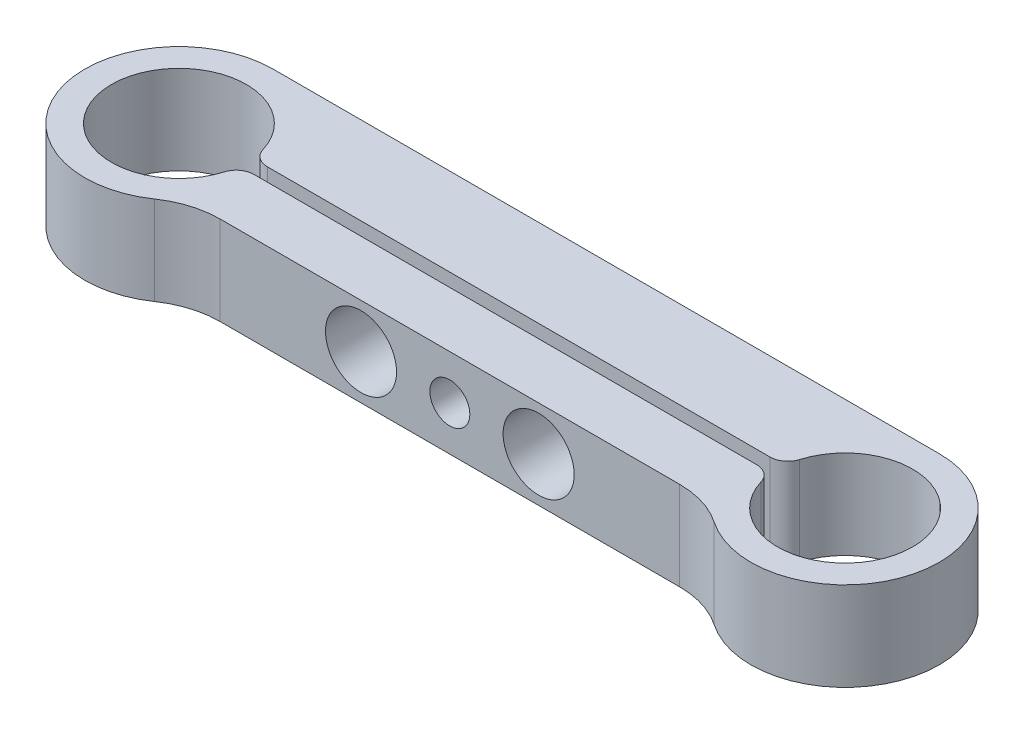
from build123d import *

# Parameters (mm, degrees)
EXTRUDE_1_DEPTH           = 10
HOLE_WIZARD_8_0_8_1_D     = 8
HOLE_WIZARD_8_0_8_1_DEPTH = 6.25
HOLE_WIZARD_M41_D         = 4.5
HOLE_WIZARD_M41_DEPTH     = 11
HOLE_WIZARD_M41_TIP       = 1.351936393
HOLE_WIZARD_M42_D         = 4.5
HOLE_WIZARD_M42_DEPTH     = 6.25
M4X0_72_D                 = 3.3
FILLET_2_R                = 10
FILLET_3_R                = 2


with BuildPart() as part:
    # Эскиз1 → Бобышка-Вытянуть1 (new body)
    with BuildSketch(Plane(origin=(0, 0, 0), x_dir=(1, 0, 0), z_dir=(0, 1, 0))):
        with BuildLine():
            Line((67.040100503, -7), (7.959899497, -7))
            ThreePointArc((7.959899497, -7), (-9.658157174, -4.368065934), (0, 10.6))
            Line((0, 10.6), (75, 10.6))
            ThreePointArc((75, 10.6), (84.658157174, -4.368065934), (67.040100503, -7))
        make_face()
        with BuildLine():
            Line((7.562902882, -0.75), (67.437097118, -0.75))
            ThreePointArc((67.437097118, -0.75), (82.6, 0), (67.437097118, 0.75))
            Line((67.437097118, 0.75), (7.562902882, 0.75))
            ThreePointArc((7.562902882, 0.75), (-7.6, 0), (7.562902882, -0.75))
        make_face(mode=Mode.SUBTRACT)
    extrude(amount=EXTRUDE_1_DEPTH)

    # Диаметр отверстия Ø8.0 (8)1
    with Locations(Plane.XY.offset(7)):
        with Locations((27.5, 5), (47.5, 5)):
            Hole(HOLE_WIZARD_8_0_8_1_D / 2, depth=HOLE_WIZARD_8_0_8_1_DEPTH)

    # Отверстие с зазором M41
    with Locations(Plane.XY.offset(-0.75)):
        with Locations((47.5, 5), (27.5, 5)):
            Hole(HOLE_WIZARD_M41_D / 2, depth=HOLE_WIZARD_M41_DEPTH)
            with Locations((0, 0, -(HOLE_WIZARD_M41_DEPTH + HOLE_WIZARD_M41_TIP / 2))):  # 118° drill point
                Cone(0, HOLE_WIZARD_M41_D / 2, HOLE_WIZARD_M41_TIP, mode=Mode.SUBTRACT)

    # Отверстие с зазором M42
    with Locations(Plane.XY.offset(7)):
        with Locations((37.5, 5)):
            Hole(HOLE_WIZARD_M42_D / 2, depth=HOLE_WIZARD_M42_DEPTH)

    # Отверстие обработанное метчиком M4x0.72 (through all)
    with Locations(Plane.XY.offset(-0.75)):
        with Locations((37.5, 5)):
            Hole(M4X0_72_D / 2)

    # Скругление2
    fillet_2_edges = [part.edges().sort_by_distance(p)[0] for p in [
        (67.040100503, 5, 7),
        (7.959899497, 5, 7),
    ]]
    fillet(fillet_2_edges, radius=FILLET_2_R)

    # Скругление3
    fillet_3_edges = [part.edges().sort_by_distance(p)[0] for p in [
        (7.562902882, 5, -0.75),
        (7.562902882, 5, 0.75),
        (67.437097118, 5, 0.75),
        (67.437097118, 5, -0.75),
    ]]
    fillet(fillet_3_edges, radius=FILLET_3_R)


solid = part.part
